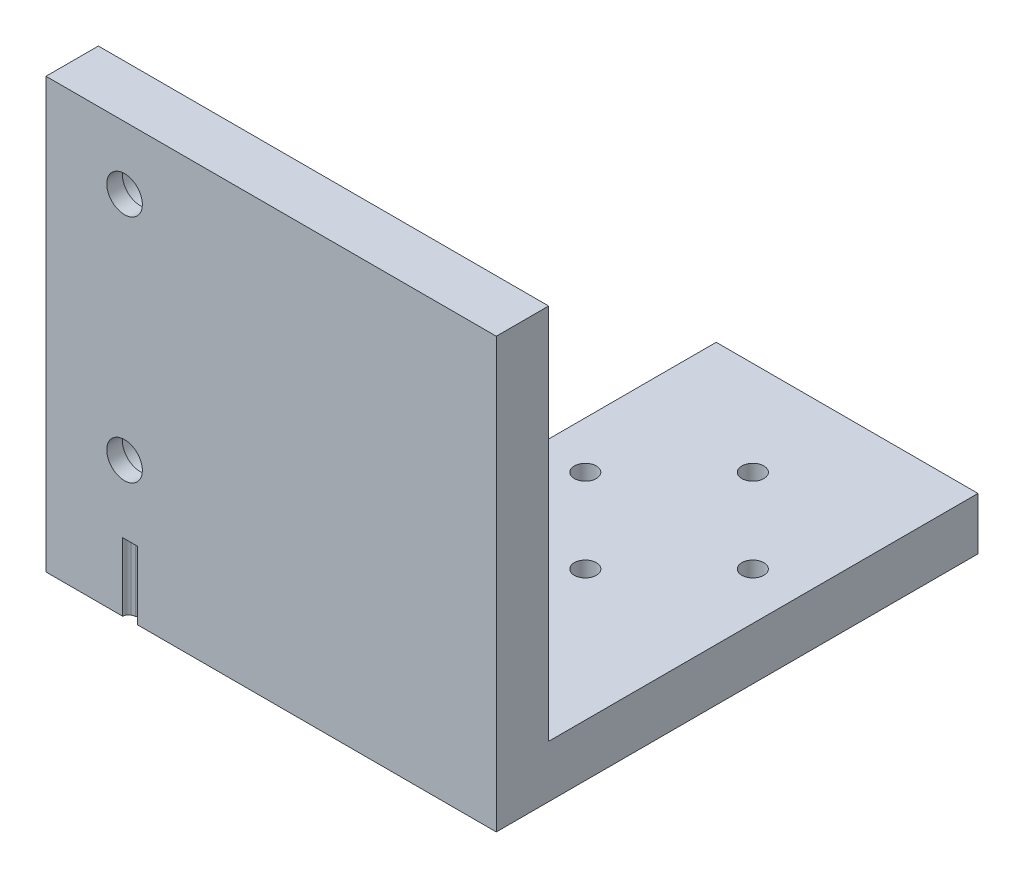
from build123d import *

# Parameters (mm, degrees)
SKETCH2_W           = 25
SKETCH2_H           = 41
BOSS_EXTRUDE1_DEPTH = 5
SKETCH4_W           = 25
SKETCH4_H           = 41
BOSS_EXTRUDE2_DEPTH = 5
SKETCH5_W           = 18
SKETCH5_H           = 5
BOSS_EXTRUDE3_DEPTH = 41
SKETCH6_R           = 2.075
CUT_EXTRUDE1_DEPTH  = 5
SKETCH11_R          = 2.075
SKETCH11_R_2        = 1.7
BOSS_EXTRUDE5_DEPTH = 1.5
SKETCH12_W          = 18
SKETCH12_H          = 6
BOSS_EXTRUDE6_DEPTH = 5
FILLET5_R           = 2
SKETCH13_R          = 2
CUT_EXTRUDE2_DEPTH  = 1.5
CUT_EXTRUDE7_DEPTH  = 6.5


with BuildPart() as part:
    # Sketch2 → Boss-Extrude1 (new body)
    with BuildSketch(Plane(origin=(0, 0, 0), x_dir=(1, 0, 0), z_dir=(0, 1, 0))):
        with Locations((0, -3.5)):
            Rectangle(SKETCH2_W, SKETCH2_H)
        with BuildLine():
            ThreePointArc((0, -6.95), (-1.05, -8), (0, -9.05))
            ThreePointArc((0, -9.05), (1.05, -8), (0, -6.95))
        make_face(mode=Mode.SUBTRACT)
        with BuildLine():
            ThreePointArc((-8, 1.05), (-9.05, 0), (-8, -1.05))
            ThreePointArc((-8, -1.05), (-6.95, 0), (-8, 1.05))
        make_face(mode=Mode.SUBTRACT)
        with BuildLine():
            ThreePointArc((8, 1.05), (6.95, 0), (8, -1.05))
            ThreePointArc((8, -1.05), (9.05, 0), (8, 1.05))
        make_face(mode=Mode.SUBTRACT)
        with BuildLine():
            ThreePointArc((0, 6.95), (1.05, 8), (0, 9.05))
            ThreePointArc((0, 9.05), (-1.05, 8), (0, 6.95))
        make_face(mode=Mode.SUBTRACT)
    extrude(amount=BOSS_EXTRUDE1_DEPTH)

    # Sketch4 → Boss-Extrude2 (add)
    with BuildSketch(Plane.XY.offset(24)):
        with Locations((0, 20.5)):
            Rectangle(SKETCH4_W, SKETCH4_H)
    extrude(amount=BOSS_EXTRUDE2_DEPTH)

    # Sketch5 → Boss-Extrude3 (add)
    with BuildSketch(Plane.XZ):
        with Locations((-21.5, 26.5)):
            Rectangle(SKETCH5_W, SKETCH5_H)
    extrude(amount=-BOSS_EXTRUDE3_DEPTH)

    # Sketch6 → Cut-Extrude1 (cut)
    with BuildSketch(Plane.XY.offset(29)):
        with Locations((-23, 13)):
            Circle(SKETCH6_R)
        with Locations((-23, 35)):
            Circle(SKETCH6_R)
    extrude(amount=-CUT_EXTRUDE1_DEPTH, mode=Mode.SUBTRACT)

    # Sketch11 → Boss-Extrude5 (add)
    with BuildSketch(Plane.XY.offset(29)):
        with Locations((-23, 13)):
            Circle(SKETCH11_R)
        with Locations((-23, 13)):
            Circle(SKETCH11_R_2, mode=Mode.SUBTRACT)
        with Locations((-23, 35)):
            Circle(SKETCH11_R)
        with Locations((-23, 35)):
            Circle(SKETCH11_R_2, mode=Mode.SUBTRACT)
    extrude(amount=-BOSS_EXTRUDE5_DEPTH)

    # Sketch12 → Boss-Extrude6 (add)
    with BuildSketch(Plane.XZ):
        with Locations((-21.5, 21)):
            Rectangle(SKETCH12_W, SKETCH12_H)
    extrude(amount=-BOSS_EXTRUDE6_DEPTH)

    # Fillet5
    fillet5_edges = [part.edges().sort_by_distance(p)[0] for p in [
        (-30.5, 2.5, 18),
    ]]
    fillet(fillet5_edges, radius=FILLET5_R)

    # Sketch13 → Cut-Extrude2 (cut)
    with BuildSketch(Plane(origin=(0, 0, 0), x_dir=(-1, 0, 0), z_dir=(0, -1, 0))):
        with Locations((0, -8)):
            Circle(SKETCH13_R)
        with Locations((8, 0)):
            Circle(SKETCH13_R)
        with Locations((0, 8)):
            Circle(SKETCH13_R)
        with Locations((-8, 0)):
            Circle(SKETCH13_R)
    extrude(amount=-CUT_EXTRUDE2_DEPTH, mode=Mode.SUBTRACT)

    # Sketch15 → Cut-Extrude7 (cut)
    with BuildSketch(Plane.XZ):
        with BuildLine():
            Line((-21.744637892, 29), (-21.744637892, 18))
            Line((-21.744637892, 18), (-21.794637892, 18))
            Line((-21.794637892, 18), (-22.424637892, 18))
            Line((-22.424637892, 18), (-22.424637892, 18.259824575))
            ThreePointArc((-22.424637892, 18.259824575), (-22.46186648, 18.358731646), (-22.555072675, 18.408543109))
            ThreePointArc((-22.555072675, 18.408543109), (-22.712700046, 18.442388286), (-22.862840139, 18.501123596))
            ThreePointArc((-22.862840139, 18.501123596), (-23.174637892, 19), (-22.862840139, 19.498876404))
            ThreePointArc((-22.862840139, 19.498876404), (-22.712700046, 19.557611714), (-22.555072675, 19.591456891))
            ThreePointArc((-22.555072675, 19.591456891), (-22.46186648, 19.641268354), (-22.424637892, 19.740175425))
            Line((-22.424637892, 19.740175425), (-22.424637892, 20.259824575))
            ThreePointArc((-22.424637892, 20.259824575), (-22.46186648, 20.358731646), (-22.555072675, 20.408543109))
            ThreePointArc((-22.555072675, 20.408543109), (-22.712700046, 20.442388286), (-22.862840139, 20.501123596))
            ThreePointArc((-22.862840139, 20.501123596), (-23.174637892, 21), (-22.862840139, 21.498876404))
            ThreePointArc((-22.862840139, 21.498876404), (-22.712700046, 21.557611714), (-22.555072675, 21.591456891))
            ThreePointArc((-22.555072675, 21.591456891), (-22.46186648, 21.641268354), (-22.424637892, 21.740175425))
            Line((-22.424637892, 21.740175425), (-22.424637892, 22.259824575))
            ThreePointArc((-22.424637892, 22.259824575), (-22.46186648, 22.358731646), (-22.555072675, 22.408543109))
            ThreePointArc((-22.555072675, 22.408543109), (-22.712700046, 22.442388286), (-22.862840139, 22.501123596))
            ThreePointArc((-22.862840139, 22.501123596), (-23.174637892, 23), (-22.862840139, 23.498876404))
            ThreePointArc((-22.862840139, 23.498876404), (-22.712700046, 23.557611714), (-22.555072675, 23.591456891))
            ThreePointArc((-22.555072675, 23.591456891), (-22.46186648, 23.641268354), (-22.424637892, 23.740175425))
            Line((-22.424637892, 23.740175425), (-22.424637892, 24.259824575))
            ThreePointArc((-22.424637892, 24.259824575), (-22.46186648, 24.358731646), (-22.555072675, 24.408543109))
            ThreePointArc((-22.555072675, 24.408543109), (-22.712700046, 24.442388286), (-22.862840139, 24.501123596))
            ThreePointArc((-22.862840139, 24.501123596), (-23.174637892, 25), (-22.862840139, 25.498876404))
            ThreePointArc((-22.862840139, 25.498876404), (-22.712700046, 25.557611714), (-22.555072675, 25.591456891))
            ThreePointArc((-22.555072675, 25.591456891), (-22.46186648, 25.641268354), (-22.424637892, 25.740175425))
            Line((-22.424637892, 25.740175425), (-22.424637892, 26.259824575))
            ThreePointArc((-22.424637892, 26.259824575), (-22.46186648, 26.358731646), (-22.555072675, 26.408543109))
            ThreePointArc((-22.555072675, 26.408543109), (-22.712700046, 26.442388286), (-22.862840139, 26.501123596))
            ThreePointArc((-22.862840139, 26.501123596), (-23.174637892, 27), (-22.862840139, 27.498876404))
            ThreePointArc((-22.862840139, 27.498876404), (-22.712700046, 27.557611714), (-22.555072675, 27.591456891))
            ThreePointArc((-22.555072675, 27.591456891), (-22.46186648, 27.641268354), (-22.424637892, 27.740175425))
            Line((-22.424637892, 27.740175425), (-22.424637892, 28.259824575))
            ThreePointArc((-22.424637892, 28.259824575), (-22.46186648, 28.358731646), (-22.555072675, 28.408543109))
            ThreePointArc((-22.555072675, 28.408543109), (-22.712700046, 28.442388286), (-22.862840139, 28.501123596))
            ThreePointArc((-22.862840139, 28.501123596), (-23.090276951, 28.705850588), (-23.174637892, 29))
            Line((-23.174637892, 29), (-21.794637892, 29))
            Line((-21.794637892, 29), (-21.744637892, 29))
        make_face()
    extrude(amount=-CUT_EXTRUDE7_DEPTH, mode=Mode.SUBTRACT)


solid = part.part
